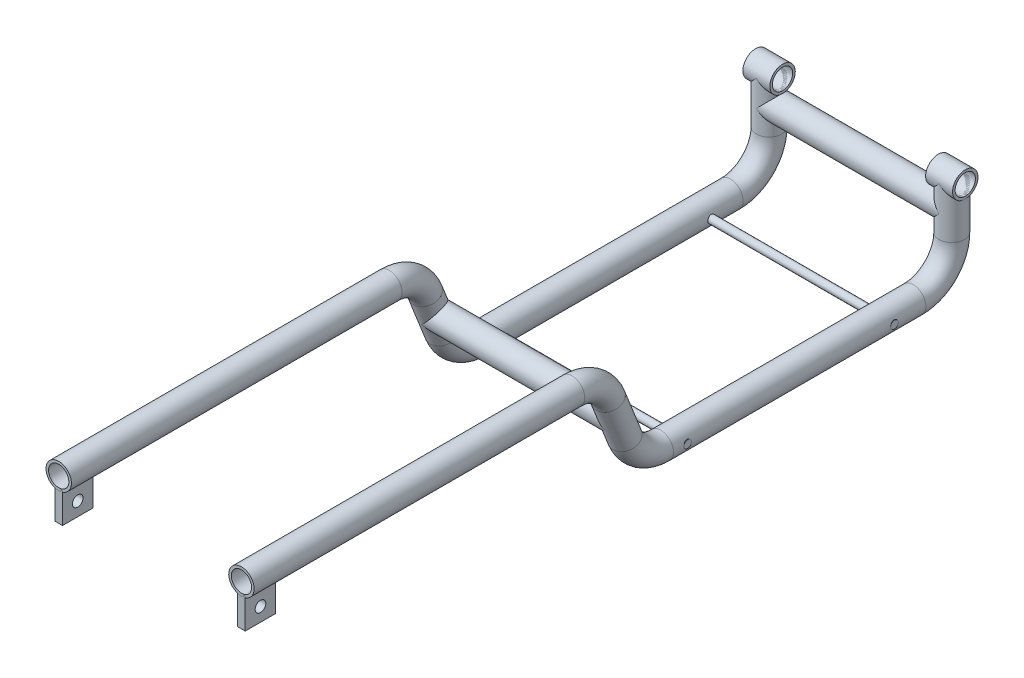
from build123d import *

# Parameters (mm, degrees)
SKETCH1_R                    = 16.7005
SKETCH1_R_2                  = 13.322299999999998
MIEMBRO_ESTRUCTURAL5_DEPTH   = 434.249581725
SKETCH1_ON_SEGMENT_2_R       = 16.7005
SKETCH1_ON_SEGMENT_2_R_2     = 13.322299999999998
MIEMBRO_ESTRUCTURAL5_2_ANGLE = 68.407307705
SKETCH1_ON_SEGMENT_3_R       = 16.7005
SKETCH1_ON_SEGMENT_3_R_2     = 13.322299999999998
MIEMBRO_ESTRUCTURAL5_3_DEPTH = 60
SKETCH1_ON_SEGMENT_4_R       = 16.7005
SKETCH1_ON_SEGMENT_4_R_2     = 13.322299999999998
MIEMBRO_ESTRUCTURAL5_4_ANGLE = 68.407307705
SKETCH1_ON_SEGMENT_5_R       = 16.7005
SKETCH1_ON_SEGMENT_5_R_2     = 13.322299999999998
MIEMBRO_ESTRUCTURAL5_5_DEPTH = 331.4
SKETCH1_ON_SEGMENT_6_R       = 16.7005
SKETCH1_ON_SEGMENT_6_R_2     = 13.322299999999998
MIEMBRO_ESTRUCTURAL5_6_ANGLE = 90
SKETCH1_ON_SEGMENT_7_R       = 16.7005
SKETCH1_ON_SEGMENT_7_R_2     = 13.322299999999998
MIEMBRO_ESTRUCTURAL5_7_DEPTH = 63.2
SKETCH12_R                   = 16.7005
SKETCH12_R_2                 = 13.322299999999998
MIEMBRO_ESTRUCTURAL2_DEPTH   = 35.4
SKETCH12_ON_SEGMENT_2_R      = 16.7005
SKETCH12_ON_SEGMENT_2_R_2    = 13.322299999999998
MIEMBRO_ESTRUCTURAL2_2_DEPTH = 35.4
SKETCH13_R                   = 16.7005
SKETCH13_R_2                 = 13.322299999999998
MIEMBRO_ESTRUCTURAL3_DEPTH   = 240
SKETCH14_R                   = 16.7005
SKETCH14_R_2                 = 13.322299999999998
MIEMBRO_ESTRUCTURAL4_DEPTH   = 240
CROQUIS8_R                   = 13.322300000000034
CORTAR_EXTRUIR1_DEPTH        = 50
CROQUIS12_W                  = 40
CROQUIS12_H                  = 39.999999999999986
CROQUIS12_R                  = 6.999999999999988
SALIENTE_EXTRUIR1_DEPTH      = 5
CROQUIS8_2_R                 = 13.322300000000034
CORTAR_EXTRUIR2_DEPTH        = 320.0000000000001
CROQUIS13_R                  = 4.99999999999999
SALIENTE_EXTRUIR2_DEPTH      = 136.7
CROQUIS13_R_2                = 5.000000000000004
SALIENTE_EXTRUIR2_2_DEPTH    = 136.7


with BuildPart() as part:
    # Sketch1 → Miembro estructural5 (new body)
    with BuildSketch(Plane(origin=(120, 120.00000000000001, 500), x_dir=(0, 1, -1e-16), z_dir=(0, -1e-16, -1))):
        Circle(SKETCH1_R)
        Circle(SKETCH1_R_2, mode=Mode.SUBTRACT)
    extrude(amount=MIEMBRO_ESTRUCTURAL5_DEPTH)


with BuildPart() as body_2:
    # Sketch1 on segment 2 (carried to the start of arc 2) → Miembro estructural5 2 (revolve)
    with BuildSketch(Plane(origin=(120, 87.894702907, 18.515388019), x_dir=(0, -0.368005963, 0.92982343), z_dir=(0, 0.92982343, 0.368005963))):
        Circle(SKETCH1_ON_SEGMENT_2_R)
        Circle(SKETCH1_ON_SEGMENT_2_R_2, mode=Mode.SUBTRACT)
    revolve(axis=Axis((120, 69.2, 65.750418275), (1, 0, 0)), revolution_arc=MIEMBRO_ESTRUCTURAL5_2_ANGLE)


with BuildPart() as body_3:
    # Sketch1 on segment 3 (carried to segment 3) → Miembro estructural5 3 (new body)
    with BuildSketch(Plane(origin=(120, 32.105297093, -3.564969745), x_dir=(0, -0.368005963, 0.92982343), z_dir=(0, 0.92982343, 0.368005963))):
        Circle(SKETCH1_ON_SEGMENT_3_R)
        Circle(SKETCH1_ON_SEGMENT_3_R_2, mode=Mode.SUBTRACT)
    extrude(amount=MIEMBRO_ESTRUCTURAL5_3_DEPTH)


with BuildPart() as body_4:
    # Sketch1 on segment 4 (carried to the start of arc 4) → Miembro estructural5 4 (revolve)
    with BuildSketch(Plane(origin=(120, 32.105297093, -3.564969745), x_dir=(0, 0.368005963, -0.92982343), z_dir=(0, -0.92982343, -0.368005963))):
        Circle(SKETCH1_ON_SEGMENT_4_R)
        Circle(SKETCH1_ON_SEGMENT_4_R_2, mode=Mode.SUBTRACT)
    revolve(axis=Axis((120, 50.8, -50.8), (1, 0, 0)), revolution_arc=MIEMBRO_ESTRUCTURAL5_4_ANGLE)


with BuildPart() as body_5:
    # Sketch1 on segment 5 (carried to segment 5) → Miembro estructural5 5 (new body)
    with BuildSketch(Plane(origin=(120, 0, -50.8), x_dir=(0, 1, 0), z_dir=(0, 0, -1))):
        Circle(SKETCH1_ON_SEGMENT_5_R)
        Circle(SKETCH1_ON_SEGMENT_5_R_2, mode=Mode.SUBTRACT)
    extrude(amount=MIEMBRO_ESTRUCTURAL5_5_DEPTH)


with BuildPart() as body_6:
    # Sketch1 on segment 6 (carried to the start of arc 6) → Miembro estructural5 6 (revolve)
    with BuildSketch(Plane(origin=(120, 0, -382.2), x_dir=(0, 1, 0), z_dir=(0, 0, -1))):
        Circle(SKETCH1_ON_SEGMENT_6_R)
        Circle(SKETCH1_ON_SEGMENT_6_R_2, mode=Mode.SUBTRACT)
    revolve(axis=Axis((120, 50.8, -382.2), (1, 0, 0)), revolution_arc=MIEMBRO_ESTRUCTURAL5_6_ANGLE)


with BuildPart() as body_7:
    # Sketch1 on segment 7 (carried to segment 7) → Miembro estructural5 7 (new body)
    with BuildSketch(Plane(origin=(120, 50.8, -433), x_dir=(0, 0, 1), z_dir=(0, 1, 0))):
        Circle(SKETCH1_ON_SEGMENT_7_R)
        Circle(SKETCH1_ON_SEGMENT_7_R_2, mode=Mode.SUBTRACT)
    extrude(amount=MIEMBRO_ESTRUCTURAL5_7_DEPTH)


with BuildPart() as body_8:
    # Sketch12 → Miembro estructural2 (new body)
    with BuildSketch(Plane(origin=(-137.7, 114, -433.0000000000001), x_dir=(0, 0, -1), z_dir=(1, 0, 0))):
        Circle(SKETCH12_R)
        Circle(SKETCH12_R_2, mode=Mode.SUBTRACT)
    extrude(amount=MIEMBRO_ESTRUCTURAL2_DEPTH)


with BuildPart() as body_9:
    # Sketch12 on segment 2 (carried to segment 2) → Miembro estructural2 2 (new body)
    with BuildSketch(Plane(origin=(102.3, 114, -433), x_dir=(0, 0, -1), z_dir=(1, 0, 0))):
        Circle(SKETCH12_ON_SEGMENT_2_R)
        Circle(SKETCH12_ON_SEGMENT_2_R_2, mode=Mode.SUBTRACT)
    extrude(amount=MIEMBRO_ESTRUCTURAL2_2_DEPTH)


with BuildPart() as body_10:
    # Sketch13 → Miembro estructural3 (new body)
    with BuildSketch(Plane(origin=(120, 60.00000000000002, 7.475209137333867), x_dir=(0, -0.3680059627309965, 0.9298234302244875), z_dir=(-1, 3e-17, -1.2e-16))):
        Circle(SKETCH13_R)
        Circle(SKETCH13_R_2, mode=Mode.SUBTRACT)
    extrude(amount=MIEMBRO_ESTRUCTURAL3_DEPTH)


with BuildPart() as body_11:
    # Sketch14 → Miembro estructural4 (new body)
    with BuildSketch(Plane(origin=(-120, 80, -433.00000000000017), x_dir=(6.9e-16, 0, -1), z_dir=(1, 0, 6.9e-16))):
        Circle(SKETCH14_R)
        Circle(SKETCH14_R_2, mode=Mode.SUBTRACT)
    extrude(amount=MIEMBRO_ESTRUCTURAL4_DEPTH)


with BuildPart() as body_12:
    # Simetría3: mirrored copy
    add(part.part.mirror(Plane(origin=(0, 0, 0), x_dir=(0, 0, 1), z_dir=(1, 0, 0))))


with BuildPart() as body_13:
    # Simetr_a3 2: mirrored copy
    add(body_2.part.mirror(Plane(origin=(0, 0, 0), x_dir=(0, 0, 1), z_dir=(1, 0, 0))))


with BuildPart() as body_14:
    # Simetr_a3 3: mirrored copy
    add(body_3.part.mirror(Plane(origin=(0, 0, 0), x_dir=(0, 0, 1), z_dir=(1, 0, 0))))


with BuildPart() as body_15:
    # Simetr_a3 4: mirrored copy
    add(body_4.part.mirror(Plane(origin=(0, 0, 0), x_dir=(0, 0, 1), z_dir=(1, 0, 0))))


with BuildPart() as body_16:
    # Simetr_a3 5: mirrored copy
    add(body_5.part.mirror(Plane(origin=(0, 0, 0), x_dir=(0, 0, 1), z_dir=(1, 0, 0))))


with BuildPart() as body_17:
    # Simetr_a3 6: mirrored copy
    add(body_6.part.mirror(Plane(origin=(0, 0, 0), x_dir=(0, 0, 1), z_dir=(1, 0, 0))))


with BuildPart() as body_18:
    # Simetr_a3 7: mirrored copy
    add(body_7.part.mirror(Plane(origin=(0, 0, 0), x_dir=(0, 0, 1), z_dir=(1, 0, 0))))

    # Croquis8_2 → Cortar-Extruir2 (cut)
    with BuildSketch(Plane(origin=(137.7, 0, 0), x_dir=(0, 0, -1), z_dir=(1, 0, 0))):
        with Locations((432.99999999999994, 114)):
            Circle(CROQUIS8_2_R)
    extrude(amount=-CORTAR_EXTRUIR2_DEPTH, mode=Mode.SUBTRACT)


with BuildPart() as body_7_1:
    add(body_7.part)

    # Croquis8 → Cortar-Extruir1 (cut)
    with BuildSketch(Plane(origin=(137.7, 0, 0), x_dir=(0, 0, -1), z_dir=(1, 0, 0))):
        with Locations((432.99999999999994, 114)):
            Circle(CROQUIS8_R)
    extrude(amount=-CORTAR_EXTRUIR1_DEPTH, mode=Mode.SUBTRACT)


with BuildPart() as body_19:
    # Croquis12 → Saliente-Extruir1 (new, symmetric)
    with BuildSketch(Plane(origin=(120, 0, 0), x_dir=(0, 0, -1), z_dir=(1, 0, 0))):
        with Locations((-480.00000000000006, 86.086392923983)):
            Rectangle(CROQUIS12_W, CROQUIS12_H)
        with Locations((-480.00000000000006, 84.086392923983)):
            Circle(CROQUIS12_R, mode=Mode.SUBTRACT)
    extrude(amount=SALIENTE_EXTRUIR1_DEPTH, both=True)


with BuildPart() as body_20:
    # Simetría5: mirrored copy
    add(body_19.part.mirror(Plane(origin=(0, 0, 0), x_dir=(0, 0, 1), z_dir=(1, 0, 0))))


with BuildPart() as body_21:
    # Croquis13 → Saliente-Extruir2 (new, symmetric)
    with BuildSketch(Plane(origin=(0, 0, 0), x_dir=(0, 0, -1), z_dir=(1, 0, 0))):
        with Locations((341.03, -4.14e-15)):
            Circle(CROQUIS13_R)
    extrude(amount=SALIENTE_EXTRUIR2_DEPTH, both=True)


with BuildPart() as body_22:
    # Croquis13 → Saliente-Extruir2 2 (new, symmetric)
    with BuildSketch(Plane(origin=(0, 0, 0), x_dir=(0, 0, -1), z_dir=(1, 0, 0))):
        with Locations((69.42, -8.42e-15)):
            Circle(CROQUIS13_R_2)
    extrude(amount=SALIENTE_EXTRUIR2_2_DEPTH, both=True)


solid = Compound([part.part, body_2.part, body_3.part, body_4.part, body_5.part, body_6.part, body_8.part, body_9.part, body_10.part, body_11.part, body_12.part, body_13.part, body_14.part, body_15.part, body_16.part, body_17.part, body_18.part, body_7_1.part, body_19.part, body_20.part, body_21.part, body_22.part])
